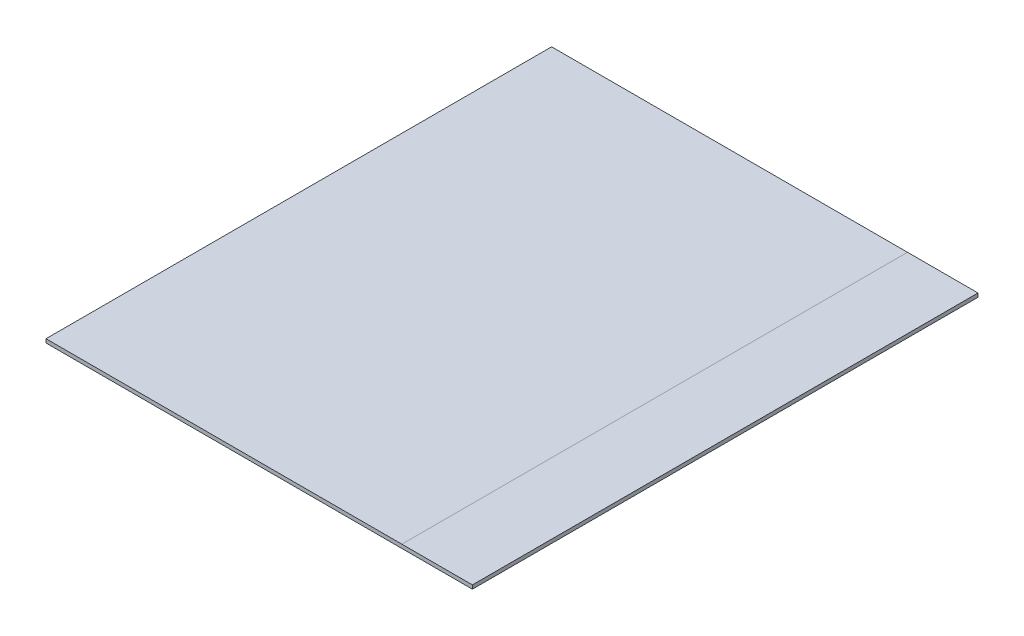
from build123d import *

# Parameters (mm, degrees)
SKETCH1_W           = 362.8
SKETCH1_H           = 430.2
BOSS_EXTRUDE1_DEPTH = 3.175


with BuildPart() as part:
    # Sketch1 → Boss-Extrude1 (new body)
    with BuildSketch(Plane(origin=(0, 0, 0), x_dir=(1, 0, 0), z_dir=(0, 1, 0))):
        with Locations((181.4, 215.1)):
            Rectangle(SKETCH1_W, SKETCH1_H)
    extrude(amount=BOSS_EXTRUDE1_DEPTH)


solid = part.part
